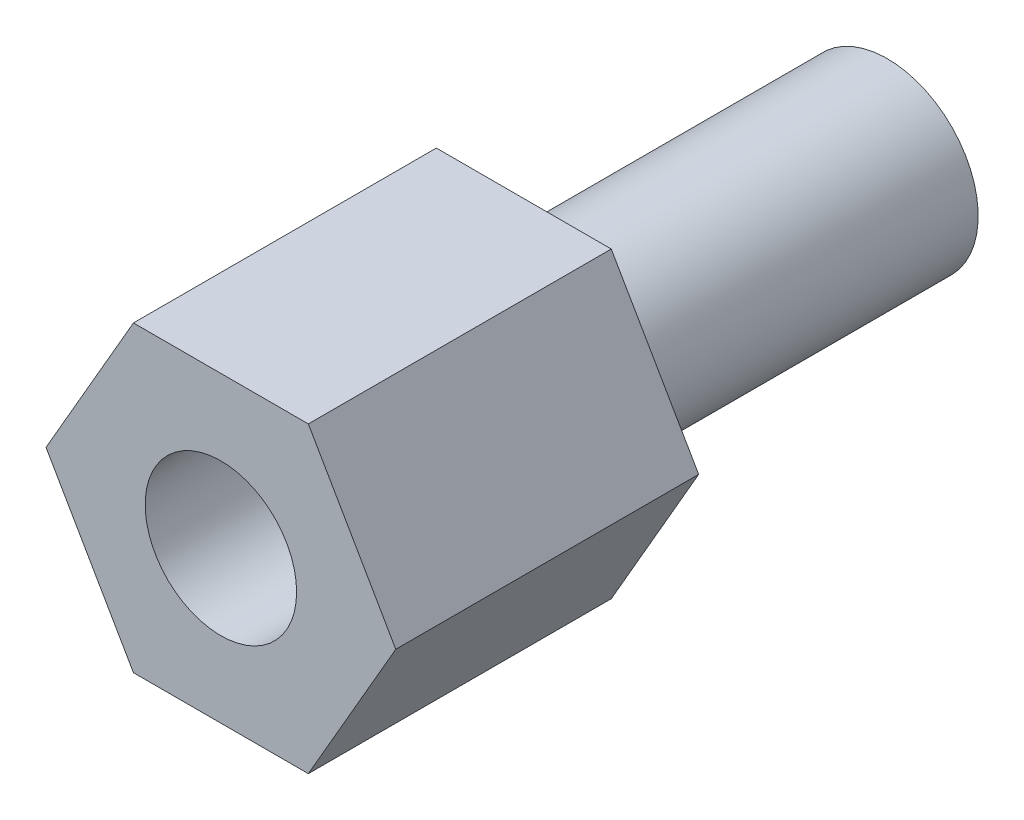
from build123d import *

# Parameters (mm, degrees)
EXTRUDE_1_DEPTH = 5
SKETCH_4_R      = 1.5
EXTRUDE_2_DEPTH = 6
M3X0_5_1_D      = 2.5
M3X0_5_1_DEPTH  = 7.5
M3X0_5_1_TIP    = 0.751075774


with BuildPart() as part:
    # 草圖1 → 填料-伸長1 (new body)
    with BuildSketch(Plane.XY):
        Polygon((-1.443375673, 2.5), (-2.886751346, 0), (-1.443375673, -2.5), (1.443375673, -2.5), (2.886751346, 0), (1.443375673, 2.5), align=None)
    extrude(amount=EXTRUDE_1_DEPTH)

    # 草圖4 → 填料-伸長2 (add)
    with BuildSketch(Plane(origin=(0, 0, 0), x_dir=(-1, 0, 0), z_dir=(0, 0, -1))):
        Circle(SKETCH_4_R)
    extrude(amount=EXTRUDE_2_DEPTH)

    # M3x0.5 螺紋孔1
    with Locations(Plane.XY.offset(5)):
        with Locations((0, 0)):
            Hole(M3X0_5_1_D / 2, depth=M3X0_5_1_DEPTH)
            with Locations((0, 0, -(M3X0_5_1_DEPTH + M3X0_5_1_TIP / 2))):  # 118° drill point
                Cone(0, M3X0_5_1_D / 2, M3X0_5_1_TIP, mode=Mode.SUBTRACT)


solid = part.part
